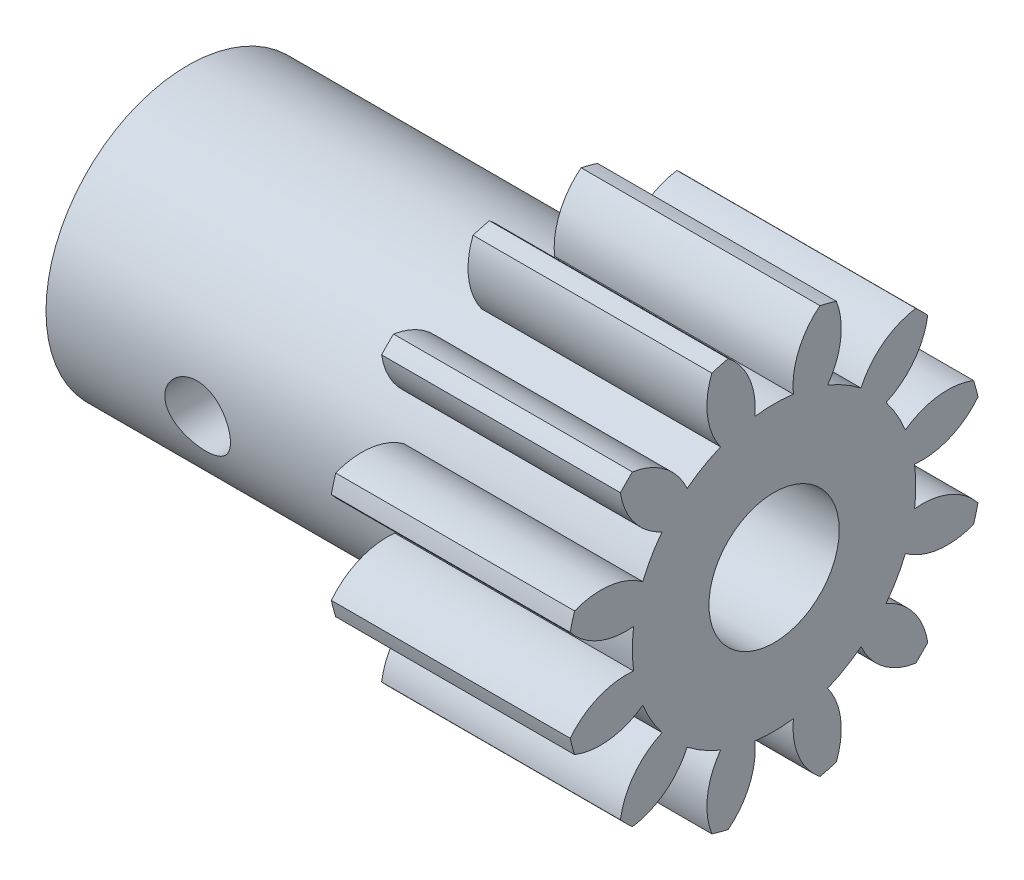
from build123d import *

# Parameters (mm, degrees)
BOSS_EXTRUDE1_DEPTH          = 11
SKETCH2_R                    = 6.53025
BOSS_EXTRUDE2_DEPTH          = 16.000051
F_6_0_6_DIAMETER_HOLE1_D     = 6
F_6_0_6_DIAMETER_HOLE1_DEPTH = 22.000051
SKETCH6_R                    = 0.016569
CUT_EXTRUDE1_DEPTH           = 80
SKETCH7_R                    = 3
CUT_EXTRUDE2_DEPTH           = 80
SKETCH8_R                    = 1.5
CUT_EXTRUDE3_DEPTH           = 11.336659
CUT_EXTRUDE3_DEPTH_BACK      = 9.444233


with BuildPart() as part:
    # Sketch1 → Boss-Extrude1 (new body)
    with BuildSketch(Plane(origin=(10.625148, 0, 0), x_dir=(0, 0, -1), z_dir=(1, 0, 0))):
        with BuildLine():
            ThreePointArc((-3.411257, 6.887327), (-4.211338, 6.495564), (-4.950655, 5.998555))
            ThreePointArc((-4.950655, 5.998555), (-5.965428, 7.279572), (-7.470402, 7.916612))
            ThreePointArc((-7.470402, 7.916612), (-7.752116, 7.646104), (-8.022623, 7.364391))
            ThreePointArc((-8.022623, 7.364391), (-7.385583, 5.859416), (-6.104566, 4.844644))
            ThreePointArc((-6.104566, 4.844644), (-6.601575, 4.105327), (-6.993338, 3.305246))
            ThreePointArc((-6.993338, 3.305246), (-8.512666, 3.907253), (-10.134532, 3.706458))
            ThreePointArc((-10.134532, 3.706458), (-10.243249, 3.331335), (-10.336659, 2.95211))
            ThreePointArc((-10.336659, 2.95211), (-9.032479, 1.967284), (-7.415699, 1.728974))
            ThreePointArc((-7.415699, 1.728974), (-7.476463, 0.840202), (-7.415699, -0.04857))
            ThreePointArc((-7.415699, -0.04857), (-9.032479, -0.28688), (-10.336659, -1.271707))
            ThreePointArc((-10.336659, -1.271707), (-10.243249, -1.650932), (-10.134532, -2.026055))
            ThreePointArc((-10.134532, -2.026055), (-8.512666, -2.226849), (-6.993338, -1.624842))
            ThreePointArc((-6.993338, -1.624842), (-6.601575, -2.424923), (-6.104566, -3.16424))
            ThreePointArc((-6.104566, -3.16424), (-7.385583, -4.179013), (-8.022623, -5.683988))
            ThreePointArc((-8.022623, -5.683988), (-7.752116, -5.965701), (-7.470402, -6.236208))
            ThreePointArc((-7.470402, -6.236208), (-5.965428, -5.599169), (-4.950655, -4.318152))
            ThreePointArc((-4.950655, -4.318152), (-4.211338, -4.815161), (-3.411257, -5.206923))
            ThreePointArc((-3.411257, -5.206923), (-4.013264, -6.726251), (-3.812469, -8.348117))
            ThreePointArc((-3.812469, -8.348117), (-3.437346, -8.456834), (-3.058122, -8.550244))
            ThreePointArc((-3.058122, -8.550244), (-2.073295, -7.246064), (-1.834985, -5.629284))
            ThreePointArc((-1.834985, -5.629284), (-0.946213, -5.690048), (-0.057441, -5.629284))
            ThreePointArc((-0.057441, -5.629284), (0.180869, -7.246064), (1.165696, -8.550244))
            ThreePointArc((1.165696, -8.550244), (1.54492, -8.456834), (1.920043, -8.348117))
            ThreePointArc((1.920043, -8.348117), (2.120838, -6.726251), (1.518831, -5.206923))
            ThreePointArc((1.518831, -5.206923), (2.318912, -4.815161), (3.058229, -4.318152))
            ThreePointArc((3.058229, -4.318152), (4.073002, -5.599169), (5.577976, -6.236208))
            ThreePointArc((5.577976, -6.236208), (5.85969, -5.965701), (6.130197, -5.683988))
            ThreePointArc((6.130197, -5.683988), (5.493157, -4.179013), (4.21214, -3.16424))
            ThreePointArc((4.21214, -3.16424), (4.709149, -2.424923), (5.100912, -1.624842))
            ThreePointArc((5.100912, -1.624842), (6.62024, -2.226849), (8.242106, -2.026055))
            ThreePointArc((8.242106, -2.026055), (8.350823, -1.650932), (8.444233, -1.271707))
            ThreePointArc((8.444233, -1.271707), (7.140053, -0.28688), (5.523273, -0.04857))
            ThreePointArc((5.523273, -0.04857), (5.584037, 0.840202), (5.523273, 1.728974))
            ThreePointArc((5.523273, 1.728974), (7.140053, 1.967284), (8.444233, 2.95211))
            ThreePointArc((8.444233, 2.95211), (8.350823, 3.331335), (8.242106, 3.706458))
            ThreePointArc((8.242106, 3.706458), (6.62024, 3.907253), (5.100912, 3.305246))
            ThreePointArc((5.100912, 3.305246), (4.709149, 4.105327), (4.21214, 4.844644))
            ThreePointArc((4.21214, 4.844644), (5.493157, 5.859416), (6.130197, 7.364391))
            ThreePointArc((6.130197, 7.364391), (5.85969, 7.646104), (5.577976, 7.916612))
            ThreePointArc((5.577976, 7.916612), (4.073002, 7.279572), (3.058229, 5.998555))
            ThreePointArc((3.058229, 5.998555), (2.318912, 6.495564), (1.518831, 6.887327))
            ThreePointArc((1.518831, 6.887327), (2.120838, 8.406654), (1.920043, 10.02852))
            ThreePointArc((1.920043, 10.02852), (1.54492, 10.137238), (1.165696, 10.230647))
            ThreePointArc((1.165696, 10.230647), (0.180869, 8.926467), (-0.057441, 7.309688))
            ThreePointArc((-0.057441, 7.309688), (-0.946213, 7.370452), (-1.834985, 7.309688))
            ThreePointArc((-1.834985, 7.309688), (-2.073295, 8.926467), (-3.058122, 10.230647))
            ThreePointArc((-3.058122, 10.230647), (-3.437346, 10.137238), (-3.812469, 10.02852))
            ThreePointArc((-3.812469, 10.02852), (-4.013264, 8.406654), (-3.411257, 6.887327))
        make_face()
    extrude(amount=-BOSS_EXTRUDE1_DEPTH)

    # Sketch2 → Boss-Extrude2 (add)
    with BuildSketch(Plane.ZY.offset(0.374852)):
        with Locations((0.946213, 0.840202)):
            Circle(SKETCH2_R)
    extrude(amount=BOSS_EXTRUDE2_DEPTH)

    # Ø6.0 (6) Diameter Hole1
    with Locations(Plane(origin=(10.625148, 0, 0), x_dir=(0, 0, -1), z_dir=(1, 0, 0))):
        with Locations((-0.946213, 0.840202)):
            Hole(F_6_0_6_DIAMETER_HOLE1_D / 2, depth=F_6_0_6_DIAMETER_HOLE1_DEPTH)

    # Sketch6 → Cut-Extrude1 (cut)
    with BuildSketch(Plane(origin=(10.625148, 0, 0), x_dir=(0, 0, -1), z_dir=(1, 0, 0))):
        with Locations((-0.399147, -2.092643)):
            Circle(SKETCH6_R)
    extrude(amount=-CUT_EXTRUDE1_DEPTH, mode=Mode.SUBTRACT)

    # Sketch7 → Cut-Extrude2 (cut)
    with BuildSketch(Plane(origin=(10.625148, 0, 0), x_dir=(0, 0, -1), z_dir=(1, 0, 0))):
        with Locations((-0.946213, 0.840202)):
            Circle(SKETCH7_R)
    extrude(amount=-CUT_EXTRUDE2_DEPTH, mode=Mode.SUBTRACT)

    # Sketch8 → Cut-Extrude3 (cut, two sides)
    with BuildSketch(Plane.XY) as cut_extrude3_sk:
        with Locations((-9.449872, 0)):
            Circle(SKETCH8_R)
    extrude(amount=CUT_EXTRUDE3_DEPTH, mode=Mode.SUBTRACT)
    extrude(cut_extrude3_sk.sketch, amount=-CUT_EXTRUDE3_DEPTH_BACK, mode=Mode.SUBTRACT)


solid = part.part
